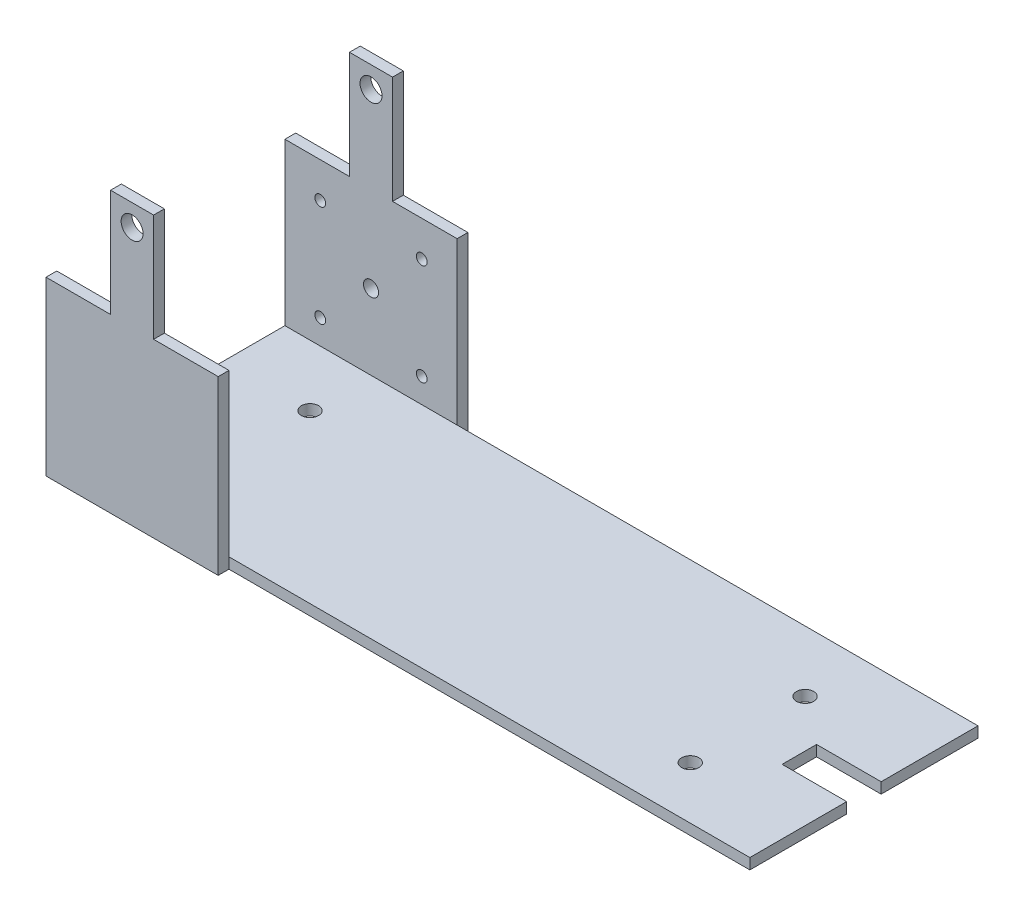
from build123d import *

# Parameters (mm, degrees)
SKETCH1_R           = 5.1
SKETCH1_R_2         = 3.5
BOSS_EXTRUDE2_DEPTH = 5
SKETCH2_R           = 2.5
CUT_EXTRUDE1_DEPTH  = 10
SKETCH3_W           = 322
SKETCH3_H           = 5
BOSS_EXTRUDE3_DEPTH = 106
SKETCH4_R           = 5.1
BOSS_EXTRUDE4_DEPTH = 5
SKETCH5_R           = 4
SKETCH5_W           = 30
SKETCH5_H           = 16
CUT_EXTRUDE2_DEPTH  = 10


with BuildPart() as part:
    # Sketch1 → Boss-Extrude2 (new body)
    with BuildSketch(Plane.XY):
        Polygon((-40, -40), (-10, -40), (-10, 10), (10, 10), (10, -40), (40, -40), (40, -120), (-40, -120), align=None)
        Circle(SKETCH1_R, mode=Mode.SUBTRACT)
        with Locations((0, -80)):
            Circle(SKETCH1_R_2, mode=Mode.SUBTRACT)
    extrude(amount=BOSS_EXTRUDE2_DEPTH)

    # Sketch2 → Cut-Extrude1 (cut)
    with BuildSketch(Plane.XY.offset(5)):
        with Locations((-23.57, -56.43)):
            Circle(SKETCH2_R)
        with Locations((23.57, -56.43)):
            Circle(SKETCH2_R)
        with Locations((-23.57, -103.57)):
            Circle(SKETCH2_R)
        with Locations((23.57, -103.57)):
            Circle(SKETCH2_R)
    extrude(amount=-CUT_EXTRUDE1_DEPTH, mode=Mode.SUBTRACT)

    # Sketch3 → Boss-Extrude3 (add)
    with BuildSketch(Plane.XY.offset(5)):
        with Locations((121, -117.5)):
            Rectangle(SKETCH3_W, SKETCH3_H)
    extrude(amount=BOSS_EXTRUDE3_DEPTH)

    # Sketch4 → Boss-Extrude4 (add)
    with BuildSketch(Plane.XY.offset(111)):
        Polygon((-40, -115), (-40, -120), (40, -120), (40, -115), (40, -40), (10, -40), (10, 10), (-10, 10), (-10, -40), (-40, -40), align=None)
        Circle(SKETCH4_R, mode=Mode.SUBTRACT)
    extrude(amount=BOSS_EXTRUDE4_DEPTH)

    # Sketch5 → Cut-Extrude2 (cut)
    with BuildSketch(Plane(origin=(0, -115, 0), x_dir=(1, 0, 0), z_dir=(0, 1, 0))):
        with Locations((0, -33.356338746)):
            Circle(SKETCH5_R)
        with Locations((0, -86.676260369)):
            Circle(SKETCH5_R)
        with Locations((230, -86.676260369)):
            Circle(SKETCH5_R)
        with Locations((230, -33.356338746)):
            Circle(SKETCH5_R)
        with Locations((267, -58)):
            Rectangle(SKETCH5_W, SKETCH5_H)
    extrude(amount=-CUT_EXTRUDE2_DEPTH, mode=Mode.SUBTRACT)


solid = part.part
